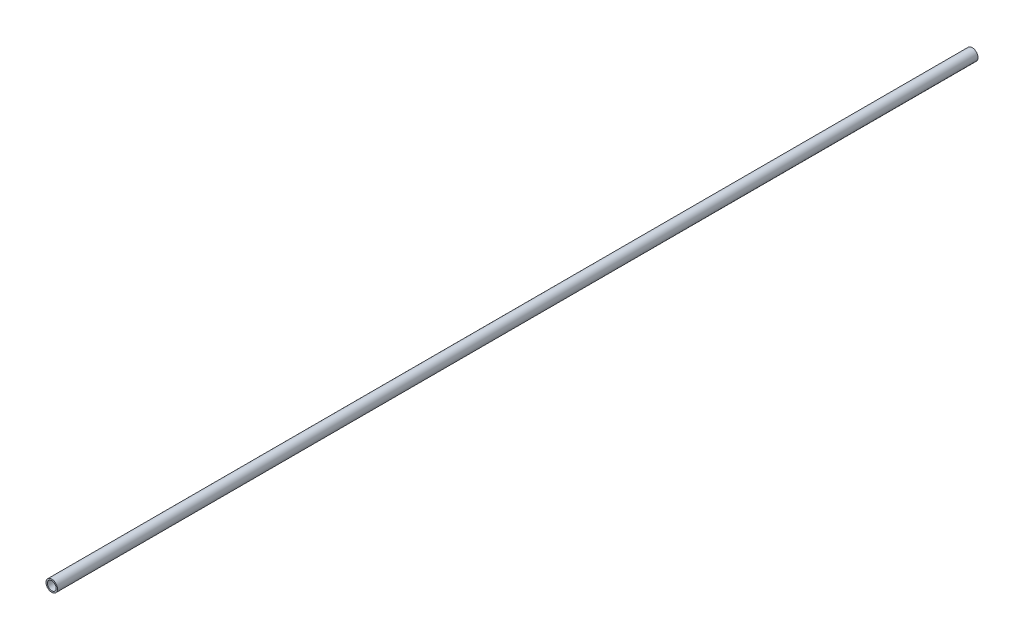
from build123d import *

# Parameters (mm, degrees)
CROQUIS1_R                   = 12.5
CROQUIS1_R_2                 = 9.5
SALIENTE_EXTRUIR1_DEPTH      = 2000
SALIENTE_EXTRUIR1_DEPTH_BACK = 3


with BuildPart() as part:
    # Croquis1 → Saliente-Extruir1 (new body, two sides)
    with BuildSketch(Plane.XY) as saliente_extruir1_sk:
        Circle(CROQUIS1_R)
        Circle(CROQUIS1_R_2, mode=Mode.SUBTRACT)
    extrude(amount=SALIENTE_EXTRUIR1_DEPTH)
    extrude(saliente_extruir1_sk.sketch, amount=-SALIENTE_EXTRUIR1_DEPTH_BACK)


solid = part.part
